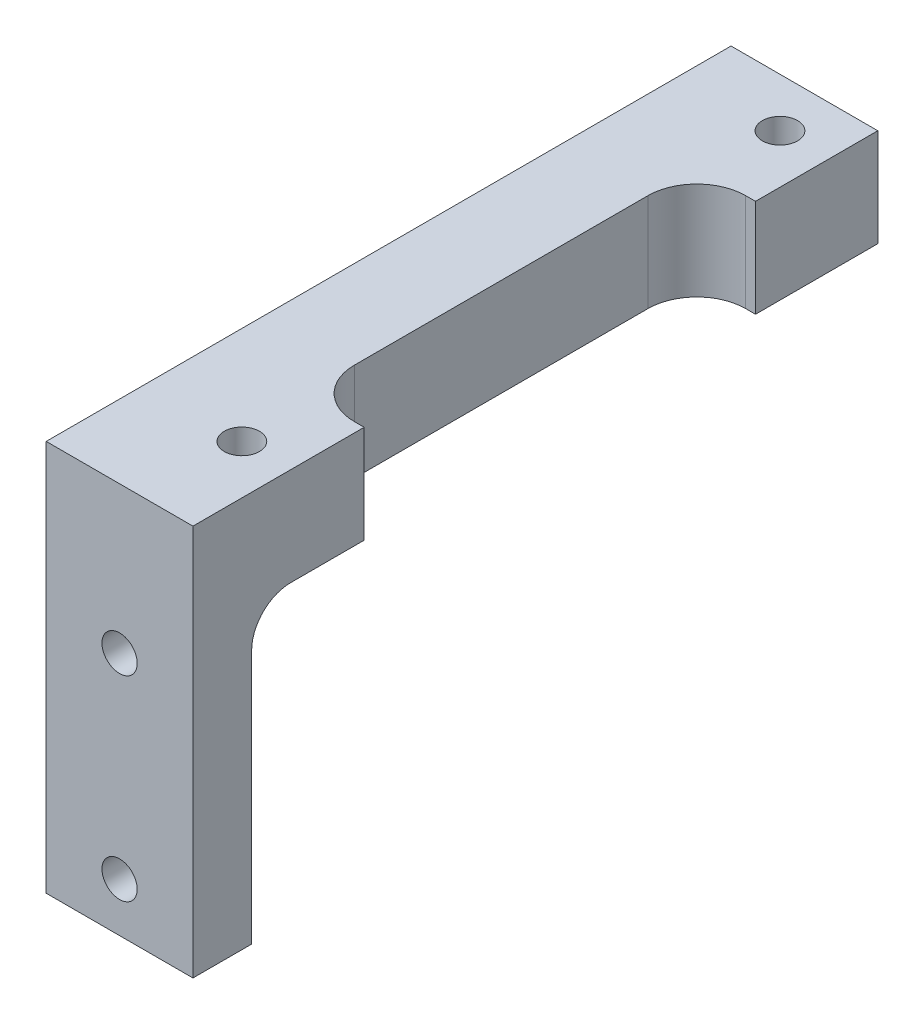
from build123d import *

# Parameters (mm, degrees)
SKETCH2_W           = 47.625
SKETCH2_H           = 25.4
BOSS_EXTRUDE1_DEPTH = 44.45
SKETCH3_W           = 28.575
SKETCH3_H           = 44.45
CUT_EXTRUDE1_DEPTH  = 26.4
SKETCH4_W           = 40.64
SKETCH4_H           = 19.05
CUT_EXTRUDE2_DEPTH  = 48.625
FILLET1_R           = 2.54
FILLET2_R           = 2.54
SKETCH5_R           = 1.143
CUT_EXTRUDE3_DEPTH  = 45.45
SKETCH6_R           = 1.143
CUT_EXTRUDE4_DEPTH  = 45.45
SKETCH7_R           = 1.143
CUT_EXTRUDE5_DEPTH  = 10.16
SKETCH8_W           = 36.195
SKETCH8_H           = 25.4
CUT_EXTRUDE6_DEPTH  = 26.4
FILLET3_R           = 3.175
FILLET4_R           = 3.175
SKETCH9_W           = 87.912640597
SKETCH9_H           = 53.774742358
CUT_EXTRUDE7_DEPTH  = 35.56


with BuildPart() as part:
    # Sketch2 → Boss-Extrude1 (new body)
    with BuildSketch(Plane.XY):
        Rectangle(SKETCH2_W, SKETCH2_H)
    extrude(amount=BOSS_EXTRUDE1_DEPTH)

    # Sketch3 → Cut-Extrude1 (cut, through all)
    with BuildSketch(Plane(origin=(0, 12.7, 0), x_dir=(1, 0, 0), z_dir=(0, 1, 0))):
        with Locations((0, -22.225)):
            Rectangle(SKETCH3_W, SKETCH3_H)
    extrude(amount=-CUT_EXTRUDE1_DEPTH, mode=Mode.SUBTRACT)

    # Sketch4 → Cut-Extrude2 (cut, through all)
    with BuildSketch(Plane.ZY.offset(23.8125)):
        with Locations((20.32, -3.175)):
            Rectangle(SKETCH4_W, SKETCH4_H)
    extrude(amount=-CUT_EXTRUDE2_DEPTH, mode=Mode.SUBTRACT)

    # Fillet1
    fillet1_edges = [part.edges().sort_by_distance(p)[0] for p in [
        (19.05, 6.35, 40.64),
    ]]
    fillet(fillet1_edges, radius=FILLET1_R)

    # Fillet2
    fillet2_edges = [part.edges().sort_by_distance(p)[0] for p in [
        (-19.05, 6.35, 40.64),
    ]]
    fillet(fillet2_edges, radius=FILLET2_R)

    # Sketch5 → Cut-Extrude3 (cut, through all)
    with BuildSketch(Plane.XY.offset(44.45)):
        with Locations((-19.05, -9.525)):
            Circle(SKETCH5_R)
        with Locations((-19.05, 3.175)):
            Circle(SKETCH5_R)
    extrude(amount=-CUT_EXTRUDE3_DEPTH, mode=Mode.SUBTRACT)

    # Sketch6 → Cut-Extrude4 (cut, through all)
    with BuildSketch(Plane.XY.offset(44.45)):
        with Locations((19.05, -9.525)):
            Circle(SKETCH6_R)
        with Locations((19.05, 3.175)):
            Circle(SKETCH6_R)
    extrude(amount=-CUT_EXTRUDE4_DEPTH, mode=Mode.SUBTRACT)

    # Sketch7 → Cut-Extrude5 (cut)
    with BuildSketch(Plane(origin=(0, 12.7, 0), x_dir=(1, 0, 0), z_dir=(0, 1, 0))):
        with Locations((-17.4625, -38.1)):
            Circle(SKETCH7_R)
        with Locations((17.4625, -38.1)):
            Circle(SKETCH7_R)
        with Locations((-17.4625, -3.175)):
            Circle(SKETCH7_R)
        with Locations((17.4625, -3.175)):
            Circle(SKETCH7_R)
    extrude(amount=-CUT_EXTRUDE5_DEPTH, mode=Mode.SUBTRACT)

    # Sketch8 → Cut-Extrude6 (cut, through all)
    with BuildSketch(Plane(origin=(0, 12.7, 0), x_dir=(1, 0, 0), z_dir=(0, 1, 0))):
        with Locations((0, -20.6375)):
            Rectangle(SKETCH8_W, SKETCH8_H)
    extrude(amount=-CUT_EXTRUDE6_DEPTH, mode=Mode.SUBTRACT)

    # Fillet3
    fillet3_edges = [part.edges().sort_by_distance(p)[0] for p in [
        (-18.0975, 9.525, 33.3375),
        (-18.0975, 9.525, 7.9375),
    ]]
    fillet(fillet3_edges, radius=FILLET3_R)

    # Fillet4
    fillet4_edges = [part.edges().sort_by_distance(p)[0] for p in [
        (18.0975, 9.525, 7.9375),
        (18.0975, 9.525, 33.3375),
    ]]
    fillet(fillet4_edges, radius=FILLET4_R)

    # Sketch9 → Cut-Extrude7 (cut)
    with BuildSketch(Plane(origin=(0, 0, 0), x_dir=(0, 0, -1), z_dir=(1, 0, 0))):
        with Locations((-24.289386177, -0.100701765)):
            Rectangle(SKETCH9_W, SKETCH9_H)
    extrude(amount=CUT_EXTRUDE7_DEPTH, mode=Mode.SUBTRACT)


solid = part.part
